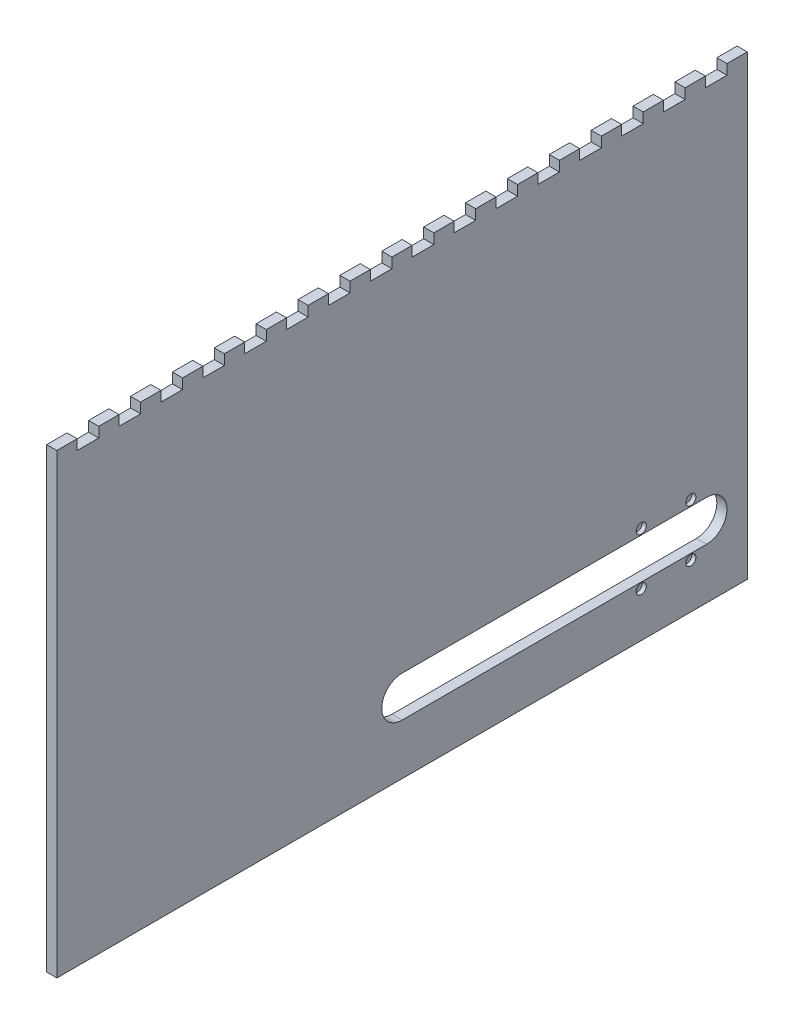
from build123d import *

# Parameters (mm, degrees)
SKETCH1_W           = 431.8
SKETCH1_H           = 285.75
BOSS_EXTRUDE1_DEPTH = 6.35
SKETCH2_W           = 431.8
SKETCH2_H           = 6.35
BOSS_EXTRUDE2_DEPTH = 12.7
CUT_EXTRUDE1_DEPTH  = 20.05
SKETCH5_W           = 51.415141408
SKETCH5_H           = 21.159166417
CUT_EXTRUDE2_DEPTH  = 432.8
SKETCH4_W           = 13.49375
SKETCH4_H           = 6.35
CUT_EXTRUDE3_DEPTH  = 6.35
CUT_EXTRUDE5_DEPTH  = 2.54


with BuildPart() as part:
    # Sketch1 → Boss-Extrude1 (new body)
    with BuildSketch(Plane(origin=(0, 0, 0), x_dir=(0, 0, -1), z_dir=(1, 0, 0))):
        Rectangle(SKETCH1_W, SKETCH1_H)
    extrude(amount=BOSS_EXTRUDE1_DEPTH)

    # Sketch2 → Boss-Extrude2 (add)
    with BuildSketch(Plane(origin=(6.35, 0, 0), x_dir=(0, 0, -1), z_dir=(1, 0, 0))):
        with Locations((0, 139.7)):
            Rectangle(SKETCH2_W, SKETCH2_H)
    extrude(amount=BOSS_EXTRUDE2_DEPTH)

    # Sketch3 → Cut-Extrude1 (cut, through all)
    with BuildSketch(Plane.ZY):
        with BuildLine():
            Line((-190.5, -85.725), (0, -85.725))
            ThreePointArc((0, -85.725), (12.7, -98.425), (0, -111.125))
            Line((0, -111.125), (-190.5, -111.125))
            ThreePointArc((-190.5, -111.125), (-203.2, -98.425), (-190.5, -85.725))
        make_face()
    extrude(amount=-CUT_EXTRUDE1_DEPTH, mode=Mode.SUBTRACT)

    # Sketch5 → Cut-Extrude2 (cut, through all)
    with BuildSketch(Plane(origin=(0, 0, -215.9), x_dir=(-1, 0, 0), z_dir=(0, 0, -1))):
        with Locations((-32.057570704, 147.104583209)):
            Rectangle(SKETCH5_W, SKETCH5_H)
    extrude(amount=-CUT_EXTRUDE2_DEPTH, mode=Mode.SUBTRACT)

    # Sketch4 → Cut-Extrude3 (cut)
    with BuildSketch(Plane.ZY):
        with Locations((-196.453125, 139.7)):
            Rectangle(SKETCH4_W, SKETCH4_H)
        with Locations((-170.259375, 139.7)):
            Rectangle(SKETCH4_W, SKETCH4_H)
        with Locations((-144.065625, 139.7)):
            Rectangle(SKETCH4_W, SKETCH4_H)
        with Locations((-117.871875, 139.7)):
            Rectangle(SKETCH4_W, SKETCH4_H)
        with Locations((-91.678125, 139.7)):
            Rectangle(SKETCH4_W, SKETCH4_H)
        with Locations((-65.484375, 139.7)):
            Rectangle(SKETCH4_W, SKETCH4_H)
        with Locations((-39.290625, 139.7)):
            Rectangle(SKETCH4_W, SKETCH4_H)
        with Locations((-13.096875, 139.7)):
            Rectangle(SKETCH4_W, SKETCH4_H)
        with Locations((13.096875, 139.7)):
            Rectangle(SKETCH4_W, SKETCH4_H)
        with Locations((39.290625, 139.7)):
            Rectangle(SKETCH4_W, SKETCH4_H)
        with Locations((65.484375, 139.7)):
            Rectangle(SKETCH4_W, SKETCH4_H)
        with Locations((91.678125, 139.7)):
            Rectangle(SKETCH4_W, SKETCH4_H)
        with Locations((117.871875, 139.7)):
            Rectangle(SKETCH4_W, SKETCH4_H)
        with Locations((144.065625, 139.7)):
            Rectangle(SKETCH4_W, SKETCH4_H)
        with Locations((170.259375, 139.7)):
            Rectangle(SKETCH4_W, SKETCH4_H)
        with Locations((196.453125, 139.7)):
            Rectangle(SKETCH4_W, SKETCH4_H)
    extrude(amount=-CUT_EXTRUDE3_DEPTH, mode=Mode.SUBTRACT)

    # Sketch6 → Cut-Extrude5 (cut)
    with BuildSketch(Plane(origin=(6.35, 0, 0), x_dir=(0, 0, -1), z_dir=(1, 0, 0))):
        with BuildLine():
            ThreePointArc((152.775, -82.06), (151.84506403, -79.81493597), (149.6, -78.885))
            ThreePointArc((149.6, -78.885), (150.660660172, -79.324339828), (151.1, -80.385))
            Line((151.1, -80.385), (151.1, -84.858325392))
            ThreePointArc((151.1, -84.858325392), (152.324254485, -83.690663209), (152.775, -82.06))
        make_face()
        with BuildLine():
            Line((148.1, -80.385), (148.1, -84.858325392))
            ThreePointArc((148.1, -84.858325392), (149.6, -85.235), (151.1, -84.858325392))
            Line((151.1, -84.858325392), (151.1, -80.385))
            ThreePointArc((151.1, -80.385), (150.660660172, -79.324339828), (149.6, -78.885))
            ThreePointArc((149.6, -78.885), (148.539339828, -79.324339828), (148.1, -80.385))
        make_face()
        with BuildLine():
            ThreePointArc((149.6, -78.885), (146.520608167, -81.286714193), (148.1, -84.858325392))
            Line((148.1, -84.858325392), (148.1, -80.385))
            ThreePointArc((148.1, -80.385), (148.539339828, -79.324339828), (149.6, -78.885))
        make_face()
        with BuildLine():
            Line((179.1, -80.385), (179.1, -84.858325392))
            ThreePointArc((179.1, -84.858325392), (180.6, -85.235), (182.1, -84.858325392))
            Line((182.1, -84.858325392), (182.1, -80.385))
            ThreePointArc((182.1, -80.385), (181.660660172, -79.324339828), (180.6, -78.885))
            ThreePointArc((180.6, -78.885), (179.539339828, -79.324339828), (179.1, -80.385))
        make_face()
        with BuildLine():
            ThreePointArc((180.6, -78.885), (177.520608167, -81.286714193), (179.1, -84.858325392))
            Line((179.1, -84.858325392), (179.1, -80.385))
            ThreePointArc((179.1, -80.385), (179.539339828, -79.324339828), (180.6, -78.885))
        make_face()
        with BuildLine():
            ThreePointArc((183.775, -82.06), (182.84506403, -79.81493597), (180.6, -78.885))
            ThreePointArc((180.6, -78.885), (181.660660172, -79.324339828), (182.1, -80.385))
            Line((182.1, -80.385), (182.1, -84.858325392))
            ThreePointArc((182.1, -84.858325392), (183.324254485, -83.690663209), (183.775, -82.06))
        make_face()
        with BuildLine():
            ThreePointArc((151.1, -116.465), (150.660660172, -117.525660172), (149.6, -117.965))
            ThreePointArc((149.6, -117.965), (151.84506403, -117.03506403), (152.775, -114.79))
            ThreePointArc((152.775, -114.79), (152.324254485, -113.159336791), (151.1, -111.991674608))
            Line((151.1, -111.991674608), (151.1, -116.465))
        make_face()
        with BuildLine():
            Line((148.1, -111.991674608), (148.1, -116.465))
            ThreePointArc((148.1, -116.465), (148.539339828, -117.525660172), (149.6, -117.965))
            ThreePointArc((149.6, -117.965), (150.660660172, -117.525660172), (151.1, -116.465))
            Line((151.1, -116.465), (151.1, -111.991674608))
            ThreePointArc((151.1, -111.991674608), (149.6, -111.615), (148.1, -111.991674608))
        make_face()
        with BuildLine():
            ThreePointArc((149.6, -117.965), (148.539339828, -117.525660172), (148.1, -116.465))
            Line((148.1, -116.465), (148.1, -111.991674608))
            ThreePointArc((148.1, -111.991674608), (146.520608167, -115.563285807), (149.6, -117.965))
        make_face()
        with BuildLine():
            ThreePointArc((180.6, -117.965), (181.660660172, -117.525660172), (182.1, -116.465))
            Line((182.1, -116.465), (182.1, -111.991674608))
            ThreePointArc((182.1, -111.991674608), (180.6, -111.615), (179.1, -111.991674608))
            Line((179.1, -111.991674608), (179.1, -116.465))
            ThreePointArc((179.1, -116.465), (179.539339828, -117.525660172), (180.6, -117.965))
        make_face()
        with BuildLine():
            Line((182.1, -111.991674608), (182.1, -116.465))
            ThreePointArc((182.1, -116.465), (181.660660172, -117.525660172), (180.6, -117.965))
            ThreePointArc((180.6, -117.965), (182.84506403, -117.03506403), (183.775, -114.79))
            ThreePointArc((183.775, -114.79), (183.324254485, -113.159336791), (182.1, -111.991674608))
        make_face()
        with BuildLine():
            ThreePointArc((179.1, -111.991674608), (177.520608167, -115.563285807), (180.6, -117.965))
            ThreePointArc((180.6, -117.965), (179.539339828, -117.525660172), (179.1, -116.465))
            Line((179.1, -116.465), (179.1, -111.991674608))
        make_face()
    extrude(amount=-CUT_EXTRUDE5_DEPTH, mode=Mode.SUBTRACT)


solid = part.part
